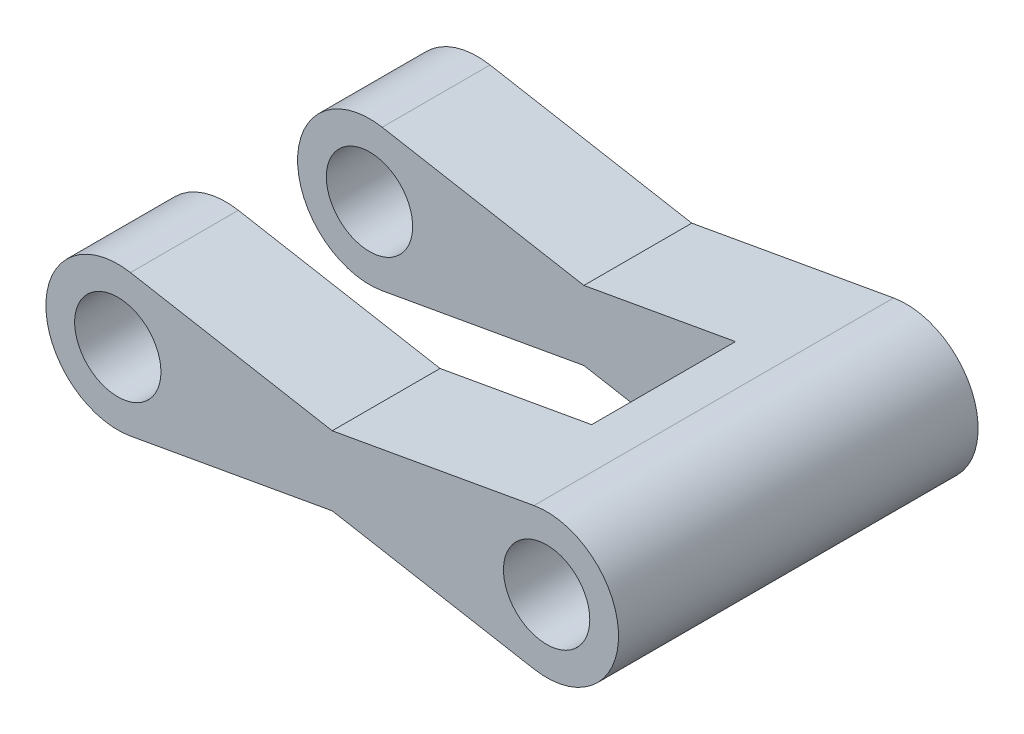
from build123d import *

# Parameters (mm, degrees)
SKETCH1_R           = 50
SKETCH1_R_2         = 30
BOSS_EXTRUDE1_DEPTH = 250
CUT_EXTRUDE1_DEPTH  = 125


with BuildPart() as part:
    # Sketch1 → Boss-Extrude1 (new body)
    with BuildSketch(Plane.XY):
        with Locations((-149.066301709, 0)):
            Circle(SKETCH1_R)
        with Locations((-149.066301709, 0)):
            Circle(SKETCH1_R_2, mode=Mode.SUBTRACT)
        with BuildLine():
            Line((0, 24.117418171), (-140.258226128, 49.218063803))
            ThreePointArc((-140.258226128, 49.218063803), (-110.72308993, 32.090467595), (-99.066301709, 0))
            ThreePointArc((-99.066301709, 0), (-110.72309003, -32.090467715), (-140.258226436, -49.218063859))
            Line((-140.258226436, -49.218063859), (0, -24.117418171))
            Line((0, -24.117418171), (140.258224826, -49.21806357))
            ThreePointArc((140.258224826, -49.21806357), (99.066301709, 3.12e-07), (140.258225441, 49.21806368))
            Line((140.258225441, 49.21806368), (0, 24.117418171))
        make_face()
        with Locations((149.066301709, 0)):
            Circle(SKETCH1_R)
        with Locations((149.066301709, 0)):
            Circle(SKETCH1_R_2, mode=Mode.SUBTRACT)
    extrude(amount=BOSS_EXTRUDE1_DEPTH)

    # Sketch2 → Cut-Extrude1 (cut, symmetric)
    with BuildSketch(Plane(origin=(0, 0, 0), x_dir=(1, 0, 0), z_dir=(0, 1, 0))):
        Polygon((-199.066301709, -75), (105.363390816, -75), (105.363390816, -125), (105.363390816, -175), (-199.066301709, -175), align=None)
    extrude(amount=CUT_EXTRUDE1_DEPTH, both=True, mode=Mode.SUBTRACT)


solid = part.part
